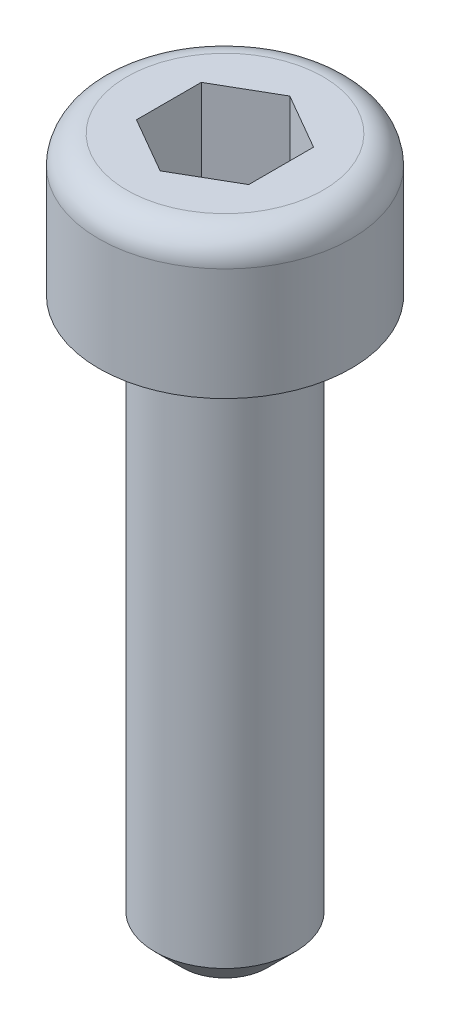
from build123d import *

# Parameters (mm, degrees)
CORTAR_EXTRUIR1_DEPTH = 2
CHAFL_N1_SIZE         = 0.5
REDONDEO1_R           = 0.5


with BuildPart() as part:
    # Croquis1 → Revolución1 (revolve)
    with BuildSketch(Plane.XY):
        Polygon((0, 0), (2.25, 0), (2.25, -2.5), (1.25, -2.5), (1.25, -12.5), (0, -12.5), align=None)
    revolve(axis=Axis((0, 0, 0), (0, -1, 0)))

    # Croquis2 → Cortar-Extruir1 (cut)
    with BuildSketch(Plane(origin=(0, 0, 0), x_dir=(1, 0, 0), z_dir=(0, 1, 0))):
        Polygon((1, 0.577350269), (0, 1.154700538), (-1, 0.577350269), (-1, -0.577350269), (0, -1.154700538), (1, -0.577350269), align=None)
    extrude(amount=-CORTAR_EXTRUIR1_DEPTH, mode=Mode.SUBTRACT)

    # Chaflán1
    chafl_n1_edges = [part.edges().sort_by_distance(p)[0] for p in [
        (-1.25, -12.5, 0),
    ]]
    chamfer(chafl_n1_edges, length=CHAFL_N1_SIZE)

    # Redondeo1
    redondeo1_edges = [part.edges().sort_by_distance(p)[0] for p in [
        (-2.25, 0, 0),
    ]]
    fillet(redondeo1_edges, radius=REDONDEO1_R)


solid = part.part
